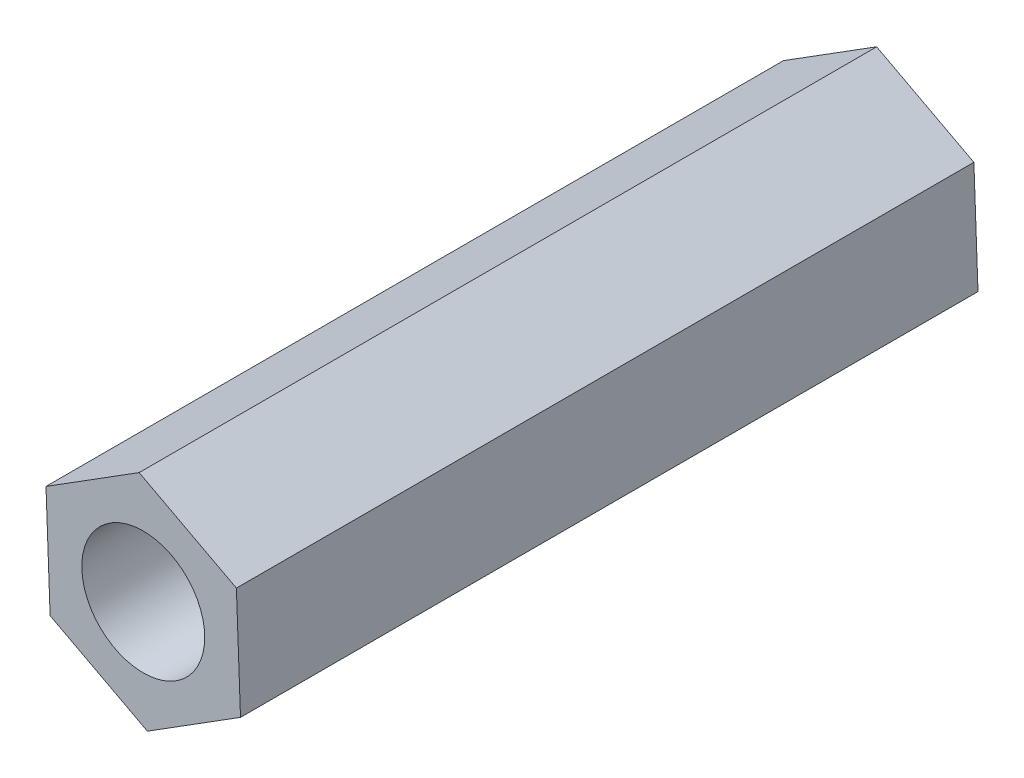
from build123d import *

# Parameters (mm, degrees)
SKETCH_1_R      = 1.5
EXTRUDE_1_DEPTH = 18


with BuildPart() as part:
    # 草图1 → 凸台-拉伸1 (new body)
    with BuildSketch(Plane.XY):
        Polygon((2.273206082, 1.428297627), (-0.100338988, 2.682803028), (-2.37354507, 1.254505402), (-2.273206082, -1.428297627), (0.100338988, -2.682803028), (2.37354507, -1.254505402), align=None)
        Circle(SKETCH_1_R, mode=Mode.SUBTRACT)
    extrude(amount=EXTRUDE_1_DEPTH)


solid = part.part
